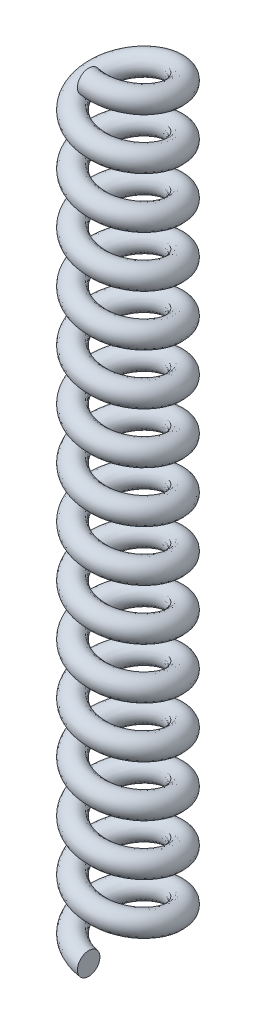
from build123d import *

# Parameters (mm, degrees)
BARRER1_PITCH  = 4.533333333
BARRER1_HEIGHT = 68
BARRER1_RADIUS = 3.5
CROQUIS2_R     = 1


with BuildPart() as part:
    # Barrer1: sweep along a helix
    with BuildLine() as barrer1_path:
        Helix(BARRER1_PITCH, BARRER1_HEIGHT, BARRER1_RADIUS, center=(0, 0, 0), direction=(0, 1, 0), lefthand=True)
    # Croquis2 → Barrer1 (sweep)
    with BuildSketch(Plane(origin=(0, 0, 0), x_dir=(0, 0, -1), z_dir=(1, 0, 0))):
        with Locations((-3.5, 0)):
            Circle(CROQUIS2_R)
    sweep(path=barrer1_path.line, is_frenet=True)


solid = part.part
